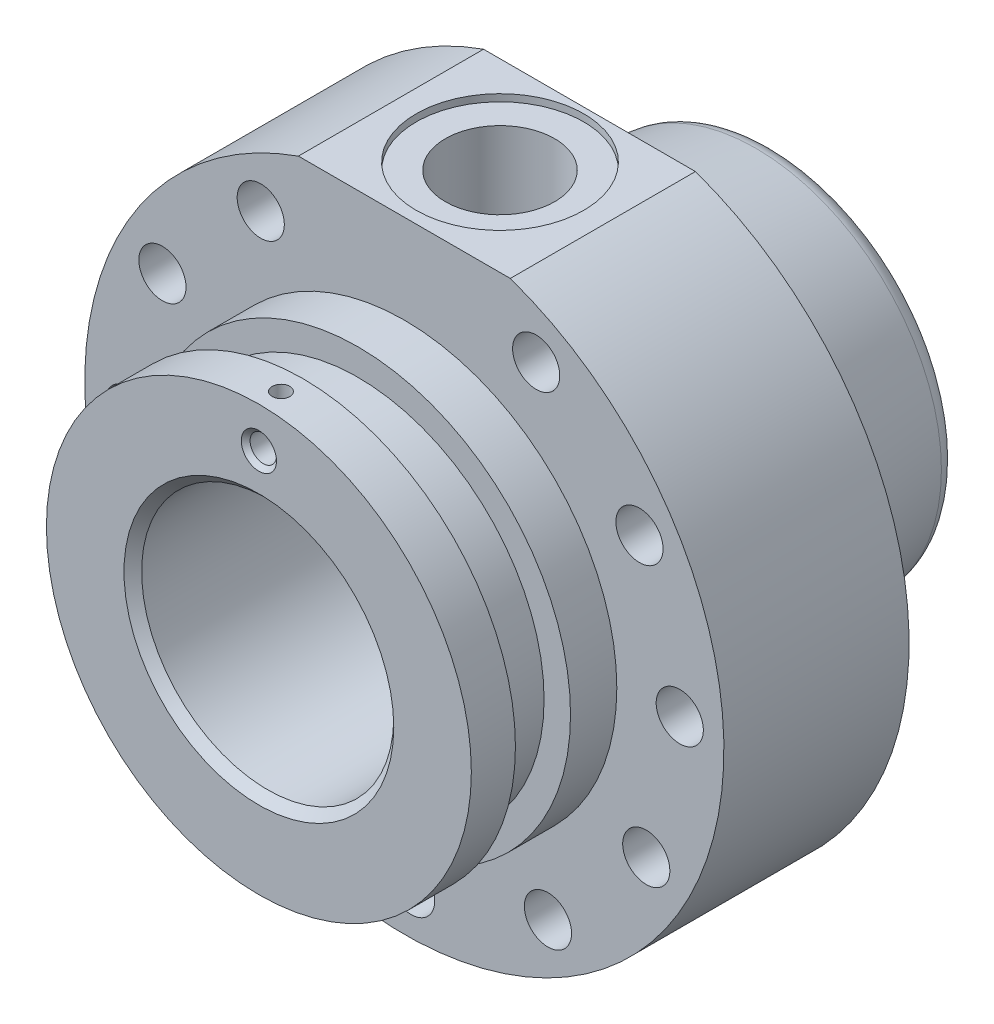
from build123d import *

# Parameters (mm, degrees)
SKETCH1_R               = 72.5
BOSS_EXTRUDE1_DEPTH     = 42
SKETCH2_R               = 48.2
BOSS_EXTRUDE2_DEPTH     = 33
SKETCH4_R               = 28.6
CUT_EXTRUDE1_DEPTH      = 156.568312969
SKETCH5_R               = 35
CUT_EXTRUDE2_DEPTH      = 8
SKETCH6_W               = 12.5
SKETCH6_H               = 6
FILLET1_R               = 5
SKETCH7_R               = 5.35
CUT_EXTRUDE3_DEPTH      = 133.546218354
CIRPATTERN1_COUNT       = 12
CHAMFER1_SIZE           = 2
SKETCH8_W               = 51
SKETCH8_H               = 57.058415431
CUT_EXTRUDE4_DEPTH      = 22
CUT_EXTRUDE4_DEPTH_BACK = 1.6
SKETCH9_R               = 19
CUT_EXTRUDE5_DEPTH      = 1.6
SKETCH10_R              = 5.35
BOSS_EXTRUDE3_DEPTH     = 42
SKETCH11_R              = 12.4
CUT_EXTRUDE6_DEPTH      = 23
SKETCH12_R              = 19
CUT_EXTRUDE7_DEPTH      = 23
SKETCH13_R              = 7.5
CUT_EXTRUDE8_DEPTH      = 23
CUT_EXTRUDE9_REACH      = 157.568
CUT_EXTRUDE9_END_RADIUS = 7.5
SKETCH14_R              = 3
CHAMFER2_SIZE           = 1
CUT_EXTRUDE10_START     = 40
SKETCH15_R              = 2
CUT_EXTRUDE10_DEPTH     = 88.033460159


with BuildPart() as part:
    # Sketch1 → Boss-Extrude1 (new body)
    with BuildSketch(Plane.XY):
        with Locations(Location((0, 0, 0), (0, 0, 180))):
            Circle(SKETCH1_R)
    extrude(amount=BOSS_EXTRUDE1_DEPTH)

    # Sketch2 → Boss-Extrude2 (add)
    with BuildSketch(Plane.XY.offset(42)):
        Circle(SKETCH2_R)
    extrude(amount=BOSS_EXTRUDE2_DEPTH)

    # Sketch3 → Revolve1 (revolve)
    with BuildSketch(Plane(origin=(0, 0, 0), x_dir=(0, 0, -1), z_dir=(1, 0, 0)), mode=Mode.PRIVATE) as revolve1_sk:
        Polygon((0, 47.6), (42, 41.5), (42, 28.6), (0, 28.6), align=None)
    revolve(revolve1_sk.sketch.rotate(Axis((0, 0, 0), (0, 0, -1)), 90), axis=Axis((0, 0, 0), (0, 0, -1)))

    # Sketch4 → Cut-Extrude1 (cut, through all)
    with BuildSketch(Plane.XY.offset(75)):
        Circle(SKETCH4_R)
    extrude(amount=-CUT_EXTRUDE1_DEPTH, mode=Mode.SUBTRACT)

    # Sketch5 → Cut-Extrude2 (cut)
    with BuildSketch(Plane(origin=(0, 0, -42), x_dir=(-1, 0, 0), z_dir=(0, 0, -1))):
        Circle(SKETCH5_R)
    extrude(amount=-CUT_EXTRUDE2_DEPTH, mode=Mode.SUBTRACT)

    # Sketch6 → Cut-Revolve1 (revolve, cut)
    with BuildSketch(Plane(origin=(0, 0, 0), x_dir=(0, 0, -1), z_dir=(1, 0, 0)), mode=Mode.PRIVATE) as cut_revolve1_sk:
        with Locations((-58.75, 45.2)):
            Rectangle(SKETCH6_W, SKETCH6_H)
    revolve(cut_revolve1_sk.sketch.rotate(Axis((0, 0, 75), (0, 0, -1)), 90), axis=Axis((0, 0, 75), (0, 0, -1)), mode=Mode.SUBTRACT)

    # Fillet1
    fillet1_edges = [part.edges().sort_by_distance(p)[0] for p in [
        (-41.5, 0, -42),
    ]]
    fillet(fillet1_edges, radius=FILLET1_R)

    # Sketch7 → Cut-Extrude3 (cut, through all)
    with BuildSketch(Plane.XY.offset(42)):
        with Locations((-1.544322391, 62.480917634)):
            Circle(SKETCH7_R)
    cut_extrude3 = extrude(amount=-CUT_EXTRUDE3_DEPTH, mode=Mode.SUBTRACT)

    # CirPattern1: Cut-Extrude3 ×12 about axis
    cirpattern1_axis = Axis((0, 0, 0), (0, 0, 1))
    for i in range(1, CIRPATTERN1_COUNT):
        add(cut_extrude3.rotate(cirpattern1_axis, i * 360 / CIRPATTERN1_COUNT), mode=Mode.SUBTRACT)

    # Chamfer1
    chamfer1_edges = [part.edges().sort_by_distance(p)[0] for p in [
        (-28.6, 0, 75),
    ]]
    chamfer(chamfer1_edges, length=CHAMFER1_SIZE)

    # Sketch8 → Cut-Extrude4 (cut, two sides)
    with BuildSketch(Plane(origin=(0, 70, 0), x_dir=(1, 0, 0), z_dir=(0, 1, 0))) as cut_extrude4_sk:
        with Locations((0, -20.682853763)):
            Rectangle(SKETCH8_W, SKETCH8_H)
    extrude(amount=CUT_EXTRUDE4_DEPTH, mode=Mode.SUBTRACT)
    extrude(cut_extrude4_sk.sketch, amount=-CUT_EXTRUDE4_DEPTH_BACK, mode=Mode.SUBTRACT)

    # Sketch9 → Cut-Extrude5 (cut)
    with BuildSketch(Plane(origin=(0, 68.4, 0), x_dir=(1, 0, 0), z_dir=(0, 1, 0))):
        with Locations(Location((0, -20.30259433, 0), (0, 0, 270))):
            Circle(SKETCH9_R)
    extrude(amount=-CUT_EXTRUDE5_DEPTH, mode=Mode.SUBTRACT)

    # Sketch10 → Boss-Extrude3 (add)
    with BuildSketch(Plane.XY.offset(42)):
        with Locations((-1.544322391, 62.480917634)):
            Circle(SKETCH10_R)
    extrude(amount=-BOSS_EXTRUDE3_DEPTH)

    # Sketch11 → Cut-Extrude6 (cut)
    with BuildSketch(Plane(origin=(0, 66.8, 0), x_dir=(1, 0, 0), z_dir=(0, 1, 0))):
        with Locations(Location((0, -20.30259433, 0), (0, 0, 270))):
            Circle(SKETCH11_R)
    extrude(amount=-CUT_EXTRUDE6_DEPTH, mode=Mode.SUBTRACT)

    # Sketch12 → Cut-Extrude7 (cut)
    with BuildSketch(Plane(origin=(0, 66.8, 0), x_dir=(1, 0, 0), z_dir=(0, 1, 0))):
        with Locations(Location((0, -20.30259433, 0), (0, 0, 270))):
            Circle(SKETCH12_R)
    extrude(amount=CUT_EXTRUDE7_DEPTH, mode=Mode.SUBTRACT)

    # Sketch13 → Cut-Extrude8 (cut)
    with BuildSketch(Plane(origin=(0, 43.8, 0), x_dir=(1, 0, 0), z_dir=(0, 1, 0))):
        with Locations(Location((0, -20.30259433, 0), (0, 0, 270))):
            Circle(SKETCH13_R)
    extrude(amount=-CUT_EXTRUDE8_DEPTH, mode=Mode.SUBTRACT)

    # Cut-Extrude9: up to this cylinder (the profile starts outside it)
    cut_extrude9_end = Plane(origin=(0, 39, 20.30259433), z_dir=(0, 1, 0)) * Cylinder(CUT_EXTRUDE9_END_RADIUS, 331.136, mode=Mode.PRIVATE)
    # Sketch14 → Cut-Extrude9 (cut, up to the surface)
    with BuildSketch(Plane.XY.offset(75), mode=Mode.PRIVATE) as cut_extrude9_sk1:
        with Locations((0, 39)):
            Circle(SKETCH14_R)
    cut_extrude9_tool1 = extrude(cut_extrude9_sk1.sketch, amount=-CUT_EXTRUDE9_REACH, mode=Mode.PRIVATE) - cut_extrude9_end
    add(cut_extrude9_tool1.solids().sort_by_distance((0, 39, 75))[0], mode=Mode.SUBTRACT)

    # Chamfer2
    chamfer2_edges = [part.edges().sort_by_distance(p)[0] for p in [
        (-3, 39, 75),
    ]]
    chamfer(chamfer2_edges, length=CHAMFER2_SIZE)

    # Sketch15 → Cut-Extrude10 (cut, through all)
    with BuildSketch(Plane(origin=(0, 0, 0), x_dir=(1, 0, 0), z_dir=(0, 1, 0)).offset(CUT_EXTRUDE10_START)):
        with Locations(Location((0, -70, 0), (0, 0, 90))):
            Circle(SKETCH15_R)
    extrude(amount=CUT_EXTRUDE10_DEPTH, mode=Mode.SUBTRACT)


solid = part.part
